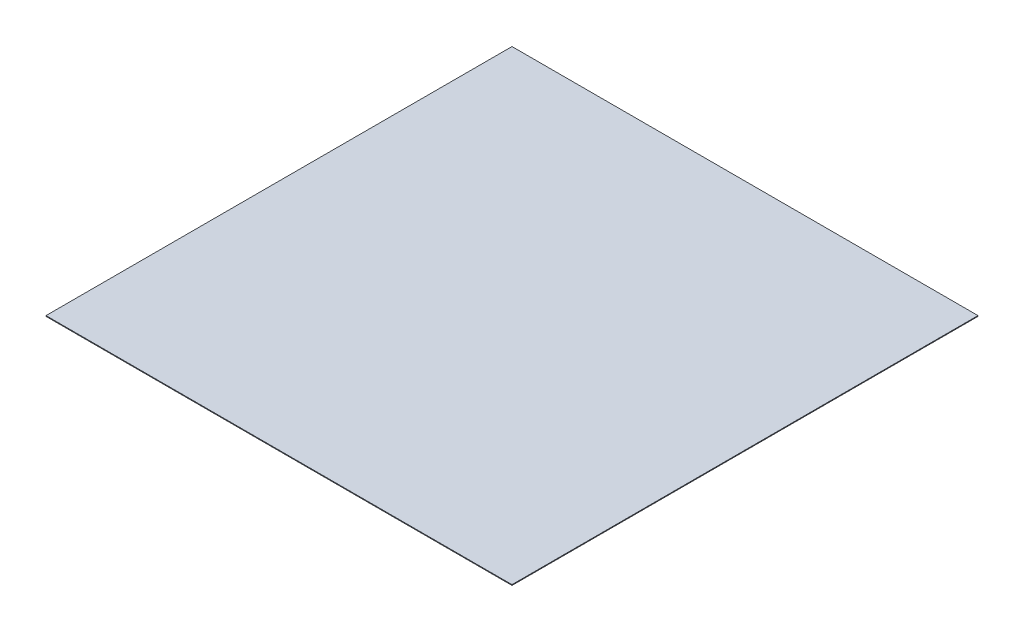
from build123d import *

# Parameters (mm, degrees)
SKETCH_1_W      = 320
SKETCH_1_H      = 320
EXTRUDE_1_DEPTH = 0.5


with BuildPart() as part:
    # 草图1 → 凸台-拉伸1 (new body)
    with BuildSketch(Plane(origin=(0, 0, 0), x_dir=(1, 0, 0), z_dir=(0, 1, 0))):
        with Locations((160, 160)):
            Rectangle(SKETCH_1_W, SKETCH_1_H)
    extrude(amount=EXTRUDE_1_DEPTH)


solid = part.part
